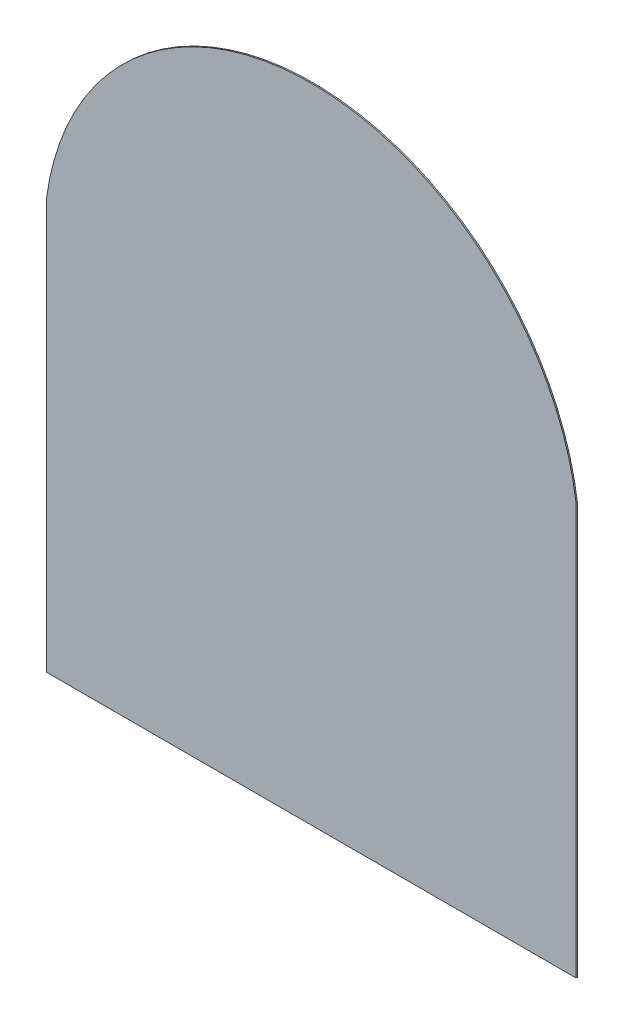
from build123d import *

# Parameters (mm, degrees)
BOSS_EXTRUDE1_DEPTH = 2.5


with BuildPart() as part:
    # Sketch1 → Boss-Extrude1 (new body, symmetric)
    with BuildSketch(Plane.XY):
        with BuildLine():
            Line((1030, 800), (1030, -800))
            Line((1030, -800), (-1030, -800))
            Line((-1030, -800), (-1030, 800))
            ThreePointArc((-1030, 800), (0, 1700), (1030, 800))
        make_face()
    extrude(amount=BOSS_EXTRUDE1_DEPTH, both=True)


solid = part.part
